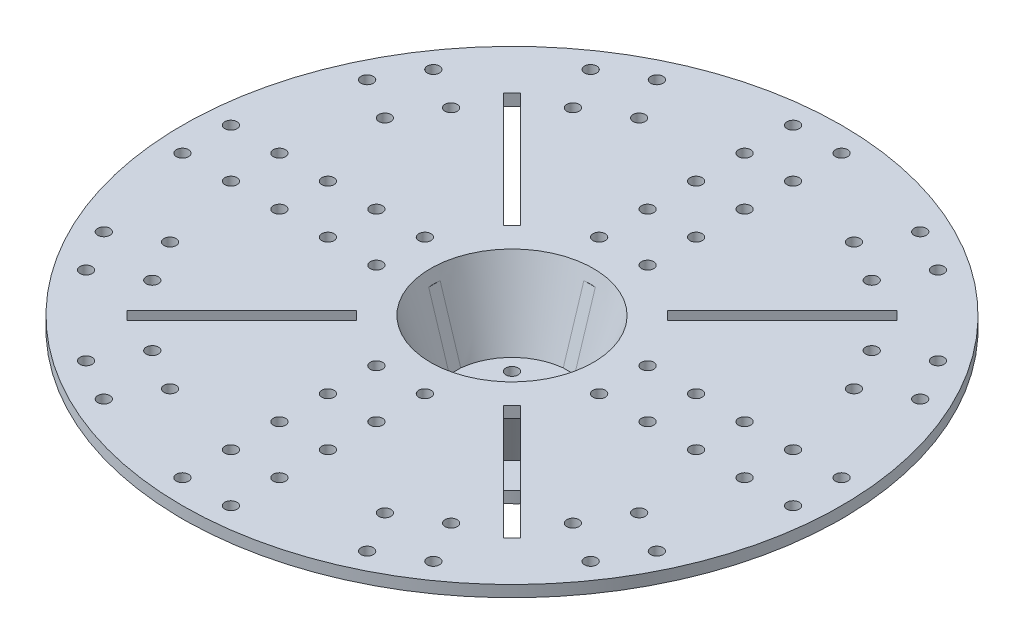
from build123d import *

# Parameters (mm, degrees)
BOSS_EXTRUDE2_DEPTH          = 3
CIRPATTERN2_COUNT            = 4
CUT_EXTRUDE3_DEPTH           = 6
CIRPATTERN4_COUNT            = 4
SKETCH7_W                    = 6
SKETCH7_H                    = 6
CUT_EXTRUDE4_DEPTH           = 34.25
SKETCH8_R                    = 3.175
CUT_EXTRUDE5_DEPTH           = 248.459028351
SKETCH11_R                   = 3.2
CUT_EXTRUDE6_DEPTH           = 248.459028351
LPATTERN2_COUNT              = 2
LPATTERN2_PITCH              = 25.4
LPATTERN2_COUNT_DIR2         = 6
LPATTERN2_PITCH_DIR2         = 25.4
CIRPATTERN5_COUNT            = 4
CIRPATTERN5_COPY_1_SKETCH_R  = 3.2
CIRPATTERN5_COPY_1_DEPTH     = 248.459028351
CIRPATTERN5_COPY_2_SKETCH_R  = 3.2
CIRPATTERN5_COPY_2_DEPTH     = 248.459028351
CIRPATTERN5_COPY_3_SKETCH_R  = 3.2
CIRPATTERN5_COPY_3_DEPTH     = 248.459028351
CIRPATTERN5_COPY_4_SKETCH_R  = 3.2
CIRPATTERN5_COPY_4_DEPTH     = 248.459028351
CIRPATTERN5_COPY_5_SKETCH_R  = 3.2
CIRPATTERN5_COPY_5_DEPTH     = 248.459028351
CIRPATTERN5_COPY_6_SKETCH_R  = 3.2
CIRPATTERN5_COPY_6_DEPTH     = 248.459028351
CIRPATTERN5_COPY_7_SKETCH_R  = 3.2
CIRPATTERN5_COPY_7_DEPTH     = 248.459028351
CIRPATTERN5_COPY_8_SKETCH_R  = 3.2
CIRPATTERN5_COPY_8_DEPTH     = 248.459028351
CIRPATTERN5_COPY_9_SKETCH_R  = 3.2
CIRPATTERN5_COPY_9_DEPTH     = 248.459028351
CIRPATTERN5_COPY_10_SKETCH_R = 3.2
CIRPATTERN5_COPY_10_DEPTH    = 248.459028351
CIRPATTERN5_COPY_11_SKETCH_R = 3.2
CIRPATTERN5_COPY_11_DEPTH    = 248.459028351
CIRPATTERN5_COPY_12_SKETCH_R = 3.2
CIRPATTERN5_COPY_12_DEPTH    = 248.459028351
CIRPATTERN5_COPY_13_SKETCH_R = 3.2
CIRPATTERN5_COPY_13_DEPTH    = 248.459028351
CIRPATTERN5_COPY_14_SKETCH_R = 3.2
CIRPATTERN5_COPY_14_DEPTH    = 248.459028351
CIRPATTERN5_COPY_15_SKETCH_R = 3.2
CIRPATTERN5_COPY_15_DEPTH    = 248.459028351
CIRPATTERN5_COPY_16_SKETCH_R = 3.2
CIRPATTERN5_COPY_16_DEPTH    = 248.459028351
CIRPATTERN5_COPY_17_SKETCH_R = 3.2
CIRPATTERN5_COPY_17_DEPTH    = 248.459028351
CIRPATTERN5_COPY_18_SKETCH_R = 3.2
CIRPATTERN5_COPY_18_DEPTH    = 248.459028351
CIRPATTERN5_COPY_19_SKETCH_R = 3.2
CIRPATTERN5_COPY_19_DEPTH    = 248.459028351
CIRPATTERN5_COPY_20_SKETCH_R = 3.2
CIRPATTERN5_COPY_20_DEPTH    = 248.459028351
CIRPATTERN5_COPY_21_SKETCH_R = 3.2
CIRPATTERN5_COPY_21_DEPTH    = 248.459028351
CIRPATTERN5_COPY_22_SKETCH_R = 3.2
CIRPATTERN5_COPY_22_DEPTH    = 248.459028351
CIRPATTERN5_COPY_23_SKETCH_R = 3.2
CIRPATTERN5_COPY_23_DEPTH    = 248.459028351
CIRPATTERN5_COPY_24_SKETCH_R = 3.2
CIRPATTERN5_COPY_24_DEPTH    = 248.459028351
CIRPATTERN5_COPY_25_SKETCH_R = 3.2
CIRPATTERN5_COPY_25_DEPTH    = 248.459028351
CIRPATTERN5_COPY_26_SKETCH_R = 3.2
CIRPATTERN5_COPY_26_DEPTH    = 248.459028351
CIRPATTERN5_COPY_27_SKETCH_R = 3.2
CIRPATTERN5_COPY_27_DEPTH    = 248.459028351
CIRPATTERN5_COPY_28_SKETCH_R = 3.2
CIRPATTERN5_COPY_28_DEPTH    = 248.459028351
CIRPATTERN5_COPY_29_SKETCH_R = 3.2
CIRPATTERN5_COPY_29_DEPTH    = 248.459028351
CIRPATTERN5_COPY_30_SKETCH_R = 3.2
CIRPATTERN5_COPY_30_DEPTH    = 248.459028351
CIRPATTERN5_COPY_31_SKETCH_R = 3.2
CIRPATTERN5_COPY_31_DEPTH    = 248.459028351
CIRPATTERN5_COPY_32_SKETCH_R = 3.2
CIRPATTERN5_COPY_32_DEPTH    = 248.459028351
CIRPATTERN5_COPY_33_SKETCH_R = 3.2
CIRPATTERN5_COPY_33_DEPTH    = 248.459028351
SKETCH17_R                   = 3.2
CUT_EXTRUDE7_DEPTH           = 249.50547421
LPATTERN3_COUNT              = 2
LPATTERN3_PITCH              = 25.4
LPATTERN3_COUNT_DIR2         = 2
LPATTERN3_PITCH_DIR2         = 25.4
MIRROR1_COPY_1_SKETCH_R      = 3.2
MIRROR1_COPY_1_DEPTH         = 249.50547421
MIRROR1_COPY_2_SKETCH_R      = 3.2
MIRROR1_COPY_2_DEPTH         = 249.50547421
MIRROR1_COPY_3_SKETCH_R      = 3.2
MIRROR1_COPY_3_DEPTH         = 249.50547421
MIRROR2_COPY_1_SKETCH_R      = 3.2
MIRROR2_COPY_1_DEPTH         = 249.50547421
MIRROR2_COPY_2_SKETCH_R      = 3.2
MIRROR2_COPY_2_DEPTH         = 249.50547421
MIRROR2_COPY_3_SKETCH_R      = 3.2
MIRROR2_COPY_3_DEPTH         = 249.50547421
MIRROR2_COPY_4_SKETCH_R      = 3.2
MIRROR2_COPY_4_DEPTH         = 249.50547421
MIRROR2_COPY_5_SKETCH_R      = 3.2
MIRROR2_COPY_5_DEPTH         = 249.50547421
MIRROR2_COPY_6_SKETCH_R      = 3.2
MIRROR2_COPY_6_DEPTH         = 249.50547421
MIRROR2_COPY_7_SKETCH_R      = 3.2
MIRROR2_COPY_7_DEPTH         = 249.50547421
CUT_EXTRUDE8_REACH           = 250.505
CIRPATTERN6_COUNT            = 4
SKETCH23_R                   = 3.2
CUT_EXTRUDE9_DEPTH           = 5.952869
CIRPATTERN7_COUNT            = 2
CIRPATTERN7_ANGLE            = 30
CIRPATTERN8_COUNT            = 4
CIRPATTERN8_COPY_1_SKETCH_R  = 3.2
CIRPATTERN8_COPY_1_DEPTH     = 5.952869
CIRPATTERN8_COPY_2_SKETCH_R  = 3.2
CIRPATTERN8_COPY_2_DEPTH     = 5.952869
CIRPATTERN8_COPY_3_SKETCH_R  = 3.2
CIRPATTERN8_COPY_3_DEPTH     = 5.952869
SKETCH26_R                   = 3.2
CUT_EXTRUDE10_DEPTH          = 249.50547421
LPATTERN4_COUNT              = 2
LPATTERN4_PITCH              = 25.4
LPATTERN4_COUNT_DIR2         = 2
LPATTERN4_PITCH_DIR2         = 25.4
MIRROR3_COPY_1_SKETCH_R      = 3.2
MIRROR3_COPY_1_DEPTH         = 249.50547421
MIRROR3_COPY_2_SKETCH_R      = 3.2
MIRROR3_COPY_2_DEPTH         = 249.50547421
MIRROR3_COPY_3_SKETCH_R      = 3.2
MIRROR3_COPY_3_DEPTH         = 249.50547421
MIRROR4_COPY_1_SKETCH_R      = 3.2
MIRROR4_COPY_1_DEPTH         = 249.50547421
MIRROR4_COPY_2_SKETCH_R      = 3.2
MIRROR4_COPY_2_DEPTH         = 249.50547421
MIRROR4_COPY_3_SKETCH_R      = 3.2
MIRROR4_COPY_3_DEPTH         = 249.50547421
MIRROR4_COPY_4_SKETCH_R      = 3.2
MIRROR4_COPY_4_DEPTH         = 249.50547421
MIRROR4_COPY_5_SKETCH_R      = 3.2
MIRROR4_COPY_5_DEPTH         = 249.50547421
MIRROR4_COPY_6_SKETCH_R      = 3.2
MIRROR4_COPY_6_DEPTH         = 249.50547421
MIRROR4_COPY_7_SKETCH_R      = 3.2
MIRROR4_COPY_7_DEPTH         = 249.50547421
CUT_EXTRUDE11_REACH          = 250.505
SKETCH27_R                   = 3.2
CIRPATTERN9_COUNT            = 4
CUT_EXTRUDE12_REACH          = 252.599
SKETCH28_W                   = 50
SKETCH28_H                   = 6.4
CIRPATTERN10_COUNT           = 4


with BuildPart() as part:
    # Sketch1 → Revolve2 (revolve)
    with BuildSketch(Plane.XY, mode=Mode.PRIVATE) as revolve2_sk:
        Polygon((0, -40.25), (0, -46.25), (55.5, -46.25), (55.5, -40.29713119), (36.117911549, -40.29713119), (46.896841146, -6), (172.649801929, -6), (172.649801929, 0), (42.649801929, 0), (30, -40.25), align=None)
    revolve(revolve2_sk.sketch.rotate(Axis((0, -40.25, 0), (0, -1, 0)), 90), axis=Axis((0, -40.25, 0), (0, -1, 0)))

    # Sketch3 → Boss-Extrude2 (add, symmetric)
    with BuildSketch(Plane.XY):
        Polygon((55.5, -40.29713119), (172.649801929, -6), (0, -6), (0, -40.29713119), align=None)
    boss_extrude2 = extrude(amount=BOSS_EXTRUDE2_DEPTH, both=True)

    # CirPattern2: Boss-Extrude2 ×4 about axis
    cirpattern2_axis = Axis((0, 0, 0), (0, 1, 0))
    for i in range(1, CIRPATTERN2_COUNT):
        add(boss_extrude2.rotate(cirpattern2_axis, i * 360 / CIRPATTERN2_COUNT))

    # Sketch6 → Cut-Extrude3 (cut)
    with BuildSketch(Plane.XY.offset(3)):
        Polygon((-3, -6), (-40.653576086, -6), (-29.849623113, -40.25), (-3, -40.25), align=None)
    cut_extrude3 = extrude(amount=-CUT_EXTRUDE3_DEPTH, mode=Mode.SUBTRACT)

    # CirPattern4: Cut-Extrude3 ×4 about axis
    cirpattern4_axis = Axis((0, 0, 0), (0, 1, 0))
    for i in range(1, CIRPATTERN4_COUNT):
        add(cut_extrude3.rotate(cirpattern4_axis, i * 360 / CIRPATTERN4_COUNT), mode=Mode.SUBTRACT)

    # Sketch7 → Cut-Extrude4 (cut)
    with BuildSketch(Plane(origin=(0, -6, 0), x_dir=(1, 0, 0), z_dir=(0, 1, 0))):
        Rectangle(SKETCH7_W, SKETCH7_H)
    extrude(amount=-CUT_EXTRUDE4_DEPTH, mode=Mode.SUBTRACT)

    # Sketch8 → Cut-Extrude5 (cut, through all)
    with BuildSketch(Plane(origin=(0, -40.25, 0), x_dir=(1, 0, 0), z_dir=(0, 1, 0))):
        with Locations(Location((0, 0, 0), (0, 0, 180))):
            Circle(SKETCH8_R)
    extrude(amount=-CUT_EXTRUDE5_DEPTH, mode=Mode.SUBTRACT)

    # Sketch11 → Cut-Extrude6 (cut, through all)
    with BuildSketch(Plane.XZ.offset(6)):
        with Locations((-12.7, 159.949801929)):
            Circle(SKETCH11_R)
    cut_extrude6 = extrude(amount=-CUT_EXTRUDE6_DEPTH, mode=Mode.SUBTRACT)

    # LPattern2: Cut-Extrude6 2 × 6
    with Locations(*[(i * LPATTERN2_PITCH, 0, -j * LPATTERN2_PITCH_DIR2) for i in range(LPATTERN2_COUNT) for j in range(LPATTERN2_COUNT_DIR2) if (i, j) != (0, 0)]):
        add(cut_extrude6, mode=Mode.SUBTRACT)

    # CirPattern5: Cut-Extrude6 ×4 about axis
    cirpattern5_axis = Axis((0, 0, 0), (0, 1, 0))
    for i in range(1, CIRPATTERN5_COUNT):
        add(cut_extrude6.rotate(cirpattern5_axis, i * 360 / CIRPATTERN5_COUNT), mode=Mode.SUBTRACT)

    # CirPattern5 copy 1 sketch → CirPattern5 copy 1 (cut, through all)
    with BuildSketch(Plane(origin=(-25.4, -6, 0), x_dir=(0, 0, -1), z_dir=(0, -1, 0))):
        with Locations((-12.7, 159.949801929)):
            Circle(CIRPATTERN5_COPY_1_SKETCH_R)
    extrude(amount=-CIRPATTERN5_COPY_1_DEPTH, mode=Mode.SUBTRACT)

    # CirPattern5 copy 2 sketch → CirPattern5 copy 2 (cut, through all)
    with BuildSketch(Plane(origin=(0, -6, 25.4), x_dir=(-1, 0, 0), z_dir=(0, -1, 0))):
        with Locations((-12.7, 159.949801929)):
            Circle(CIRPATTERN5_COPY_2_SKETCH_R)
    extrude(amount=-CIRPATTERN5_COPY_2_DEPTH, mode=Mode.SUBTRACT)

    # CirPattern5 copy 3 sketch → CirPattern5 copy 3 (cut, through all)
    with BuildSketch(Plane(origin=(25.4, -6, 0), x_dir=(0, 0, 1), z_dir=(0, -1, 0))):
        with Locations((-12.7, 159.949801929)):
            Circle(CIRPATTERN5_COPY_3_SKETCH_R)
    extrude(amount=-CIRPATTERN5_COPY_3_DEPTH, mode=Mode.SUBTRACT)

    # CirPattern5 copy 4 sketch → CirPattern5 copy 4 (cut, through all)
    with BuildSketch(Plane(origin=(-50.8, -6, 0), x_dir=(0, 0, -1), z_dir=(0, -1, 0))):
        with Locations((-12.7, 159.949801929)):
            Circle(CIRPATTERN5_COPY_4_SKETCH_R)
    extrude(amount=-CIRPATTERN5_COPY_4_DEPTH, mode=Mode.SUBTRACT)

    # CirPattern5 copy 5 sketch → CirPattern5 copy 5 (cut, through all)
    with BuildSketch(Plane(origin=(0, -6, 50.8), x_dir=(-1, 0, 0), z_dir=(0, -1, 0))):
        with Locations((-12.7, 159.949801929)):
            Circle(CIRPATTERN5_COPY_5_SKETCH_R)
    extrude(amount=-CIRPATTERN5_COPY_5_DEPTH, mode=Mode.SUBTRACT)

    # CirPattern5 copy 6 sketch → CirPattern5 copy 6 (cut, through all)
    with BuildSketch(Plane(origin=(50.8, -6, 0), x_dir=(0, 0, 1), z_dir=(0, -1, 0))):
        with Locations((-12.7, 159.949801929)):
            Circle(CIRPATTERN5_COPY_6_SKETCH_R)
    extrude(amount=-CIRPATTERN5_COPY_6_DEPTH, mode=Mode.SUBTRACT)

    # CirPattern5 copy 7 sketch → CirPattern5 copy 7 (cut, through all)
    with BuildSketch(Plane(origin=(-76.2, -6, 0), x_dir=(0, 0, -1), z_dir=(0, -1, 0))):
        with Locations((-12.7, 159.949801929)):
            Circle(CIRPATTERN5_COPY_7_SKETCH_R)
    extrude(amount=-CIRPATTERN5_COPY_7_DEPTH, mode=Mode.SUBTRACT)

    # CirPattern5 copy 8 sketch → CirPattern5 copy 8 (cut, through all)
    with BuildSketch(Plane(origin=(0, -6, 76.2), x_dir=(-1, 0, 0), z_dir=(0, -1, 0))):
        with Locations((-12.7, 159.949801929)):
            Circle(CIRPATTERN5_COPY_8_SKETCH_R)
    extrude(amount=-CIRPATTERN5_COPY_8_DEPTH, mode=Mode.SUBTRACT)

    # CirPattern5 copy 9 sketch → CirPattern5 copy 9 (cut, through all)
    with BuildSketch(Plane(origin=(76.2, -6, 0), x_dir=(0, 0, 1), z_dir=(0, -1, 0))):
        with Locations((-12.7, 159.949801929)):
            Circle(CIRPATTERN5_COPY_9_SKETCH_R)
    extrude(amount=-CIRPATTERN5_COPY_9_DEPTH, mode=Mode.SUBTRACT)

    # CirPattern5 copy 10 sketch → CirPattern5 copy 10 (cut, through all)
    with BuildSketch(Plane(origin=(-101.6, -6, 0), x_dir=(0, 0, -1), z_dir=(0, -1, 0))):
        with Locations((-12.7, 159.949801929)):
            Circle(CIRPATTERN5_COPY_10_SKETCH_R)
    extrude(amount=-CIRPATTERN5_COPY_10_DEPTH, mode=Mode.SUBTRACT)

    # CirPattern5 copy 11 sketch → CirPattern5 copy 11 (cut, through all)
    with BuildSketch(Plane(origin=(0, -6, 101.6), x_dir=(-1, 0, 0), z_dir=(0, -1, 0))):
        with Locations((-12.7, 159.949801929)):
            Circle(CIRPATTERN5_COPY_11_SKETCH_R)
    extrude(amount=-CIRPATTERN5_COPY_11_DEPTH, mode=Mode.SUBTRACT)

    # CirPattern5 copy 12 sketch → CirPattern5 copy 12 (cut, through all)
    with BuildSketch(Plane(origin=(101.6, -6, 0), x_dir=(0, 0, 1), z_dir=(0, -1, 0))):
        with Locations((-12.7, 159.949801929)):
            Circle(CIRPATTERN5_COPY_12_SKETCH_R)
    extrude(amount=-CIRPATTERN5_COPY_12_DEPTH, mode=Mode.SUBTRACT)

    # CirPattern5 copy 13 sketch → CirPattern5 copy 13 (cut, through all)
    with BuildSketch(Plane(origin=(-127, -6, 0), x_dir=(0, 0, -1), z_dir=(0, -1, 0))):
        with Locations((-12.7, 159.949801929)):
            Circle(CIRPATTERN5_COPY_13_SKETCH_R)
    extrude(amount=-CIRPATTERN5_COPY_13_DEPTH, mode=Mode.SUBTRACT)

    # CirPattern5 copy 14 sketch → CirPattern5 copy 14 (cut, through all)
    with BuildSketch(Plane(origin=(0, -6, 127), x_dir=(-1, 0, 0), z_dir=(0, -1, 0))):
        with Locations((-12.7, 159.949801929)):
            Circle(CIRPATTERN5_COPY_14_SKETCH_R)
    extrude(amount=-CIRPATTERN5_COPY_14_DEPTH, mode=Mode.SUBTRACT)

    # CirPattern5 copy 15 sketch → CirPattern5 copy 15 (cut, through all)
    with BuildSketch(Plane(origin=(127, -6, 0), x_dir=(0, 0, 1), z_dir=(0, -1, 0))):
        with Locations((-12.7, 159.949801929)):
            Circle(CIRPATTERN5_COPY_15_SKETCH_R)
    extrude(amount=-CIRPATTERN5_COPY_15_DEPTH, mode=Mode.SUBTRACT)

    # CirPattern5 copy 16 sketch → CirPattern5 copy 16 (cut, through all)
    with BuildSketch(Plane(origin=(0, -6, -25.4), x_dir=(0, 0, -1), z_dir=(0, -1, 0))):
        with Locations((-12.7, 159.949801929)):
            Circle(CIRPATTERN5_COPY_16_SKETCH_R)
    extrude(amount=-CIRPATTERN5_COPY_16_DEPTH, mode=Mode.SUBTRACT)

    # CirPattern5 copy 17 sketch → CirPattern5 copy 17 (cut, through all)
    with BuildSketch(Plane(origin=(-25.4, -6, 0), x_dir=(-1, 0, 0), z_dir=(0, -1, 0))):
        with Locations((-12.7, 159.949801929)):
            Circle(CIRPATTERN5_COPY_17_SKETCH_R)
    extrude(amount=-CIRPATTERN5_COPY_17_DEPTH, mode=Mode.SUBTRACT)

    # CirPattern5 copy 18 sketch → CirPattern5 copy 18 (cut, through all)
    with BuildSketch(Plane(origin=(0, -6, 25.4), x_dir=(0, 0, 1), z_dir=(0, -1, 0))):
        with Locations((-12.7, 159.949801929)):
            Circle(CIRPATTERN5_COPY_18_SKETCH_R)
    extrude(amount=-CIRPATTERN5_COPY_18_DEPTH, mode=Mode.SUBTRACT)

    # CirPattern5 copy 19 sketch → CirPattern5 copy 19 (cut, through all)
    with BuildSketch(Plane(origin=(-25.4, -6, -25.4), x_dir=(0, 0, -1), z_dir=(0, -1, 0))):
        with Locations((-12.7, 159.949801929)):
            Circle(CIRPATTERN5_COPY_19_SKETCH_R)
    extrude(amount=-CIRPATTERN5_COPY_19_DEPTH, mode=Mode.SUBTRACT)

    # CirPattern5 copy 20 sketch → CirPattern5 copy 20 (cut, through all)
    with BuildSketch(Plane(origin=(-25.4, -6, 25.4), x_dir=(-1, 0, 0), z_dir=(0, -1, 0))):
        with Locations((-12.7, 159.949801929)):
            Circle(CIRPATTERN5_COPY_20_SKETCH_R)
    extrude(amount=-CIRPATTERN5_COPY_20_DEPTH, mode=Mode.SUBTRACT)

    # CirPattern5 copy 21 sketch → CirPattern5 copy 21 (cut, through all)
    with BuildSketch(Plane(origin=(25.4, -6, 25.4), x_dir=(0, 0, 1), z_dir=(0, -1, 0))):
        with Locations((-12.7, 159.949801929)):
            Circle(CIRPATTERN5_COPY_21_SKETCH_R)
    extrude(amount=-CIRPATTERN5_COPY_21_DEPTH, mode=Mode.SUBTRACT)

    # CirPattern5 copy 22 sketch → CirPattern5 copy 22 (cut, through all)
    with BuildSketch(Plane(origin=(-50.8, -6, -25.4), x_dir=(0, 0, -1), z_dir=(0, -1, 0))):
        with Locations((-12.7, 159.949801929)):
            Circle(CIRPATTERN5_COPY_22_SKETCH_R)
    extrude(amount=-CIRPATTERN5_COPY_22_DEPTH, mode=Mode.SUBTRACT)

    # CirPattern5 copy 23 sketch → CirPattern5 copy 23 (cut, through all)
    with BuildSketch(Plane(origin=(-25.4, -6, 50.8), x_dir=(-1, 0, 0), z_dir=(0, -1, 0))):
        with Locations((-12.7, 159.949801929)):
            Circle(CIRPATTERN5_COPY_23_SKETCH_R)
    extrude(amount=-CIRPATTERN5_COPY_23_DEPTH, mode=Mode.SUBTRACT)

    # CirPattern5 copy 24 sketch → CirPattern5 copy 24 (cut, through all)
    with BuildSketch(Plane(origin=(50.8, -6, 25.4), x_dir=(0, 0, 1), z_dir=(0, -1, 0))):
        with Locations((-12.7, 159.949801929)):
            Circle(CIRPATTERN5_COPY_24_SKETCH_R)
    extrude(amount=-CIRPATTERN5_COPY_24_DEPTH, mode=Mode.SUBTRACT)

    # CirPattern5 copy 25 sketch → CirPattern5 copy 25 (cut, through all)
    with BuildSketch(Plane(origin=(-76.2, -6, -25.4), x_dir=(0, 0, -1), z_dir=(0, -1, 0))):
        with Locations((-12.7, 159.949801929)):
            Circle(CIRPATTERN5_COPY_25_SKETCH_R)
    extrude(amount=-CIRPATTERN5_COPY_25_DEPTH, mode=Mode.SUBTRACT)

    # CirPattern5 copy 26 sketch → CirPattern5 copy 26 (cut, through all)
    with BuildSketch(Plane(origin=(-25.4, -6, 76.2), x_dir=(-1, 0, 0), z_dir=(0, -1, 0))):
        with Locations((-12.7, 159.949801929)):
            Circle(CIRPATTERN5_COPY_26_SKETCH_R)
    extrude(amount=-CIRPATTERN5_COPY_26_DEPTH, mode=Mode.SUBTRACT)

    # CirPattern5 copy 27 sketch → CirPattern5 copy 27 (cut, through all)
    with BuildSketch(Plane(origin=(76.2, -6, 25.4), x_dir=(0, 0, 1), z_dir=(0, -1, 0))):
        with Locations((-12.7, 159.949801929)):
            Circle(CIRPATTERN5_COPY_27_SKETCH_R)
    extrude(amount=-CIRPATTERN5_COPY_27_DEPTH, mode=Mode.SUBTRACT)

    # CirPattern5 copy 28 sketch → CirPattern5 copy 28 (cut, through all)
    with BuildSketch(Plane(origin=(-101.6, -6, -25.4), x_dir=(0, 0, -1), z_dir=(0, -1, 0))):
        with Locations((-12.7, 159.949801929)):
            Circle(CIRPATTERN5_COPY_28_SKETCH_R)
    extrude(amount=-CIRPATTERN5_COPY_28_DEPTH, mode=Mode.SUBTRACT)

    # CirPattern5 copy 29 sketch → CirPattern5 copy 29 (cut, through all)
    with BuildSketch(Plane(origin=(-25.4, -6, 101.6), x_dir=(-1, 0, 0), z_dir=(0, -1, 0))):
        with Locations((-12.7, 159.949801929)):
            Circle(CIRPATTERN5_COPY_29_SKETCH_R)
    extrude(amount=-CIRPATTERN5_COPY_29_DEPTH, mode=Mode.SUBTRACT)

    # CirPattern5 copy 30 sketch → CirPattern5 copy 30 (cut, through all)
    with BuildSketch(Plane(origin=(101.6, -6, 25.4), x_dir=(0, 0, 1), z_dir=(0, -1, 0))):
        with Locations((-12.7, 159.949801929)):
            Circle(CIRPATTERN5_COPY_30_SKETCH_R)
    extrude(amount=-CIRPATTERN5_COPY_30_DEPTH, mode=Mode.SUBTRACT)

    # CirPattern5 copy 31 sketch → CirPattern5 copy 31 (cut, through all)
    with BuildSketch(Plane(origin=(-127, -6, -25.4), x_dir=(0, 0, -1), z_dir=(0, -1, 0))):
        with Locations((-12.7, 159.949801929)):
            Circle(CIRPATTERN5_COPY_31_SKETCH_R)
    extrude(amount=-CIRPATTERN5_COPY_31_DEPTH, mode=Mode.SUBTRACT)

    # CirPattern5 copy 32 sketch → CirPattern5 copy 32 (cut, through all)
    with BuildSketch(Plane(origin=(-25.4, -6, 127), x_dir=(-1, 0, 0), z_dir=(0, -1, 0))):
        with Locations((-12.7, 159.949801929)):
            Circle(CIRPATTERN5_COPY_32_SKETCH_R)
    extrude(amount=-CIRPATTERN5_COPY_32_DEPTH, mode=Mode.SUBTRACT)

    # CirPattern5 copy 33 sketch → CirPattern5 copy 33 (cut, through all)
    with BuildSketch(Plane(origin=(127, -6, 25.4), x_dir=(0, 0, 1), z_dir=(0, -1, 0))):
        with Locations((-12.7, 159.949801929)):
            Circle(CIRPATTERN5_COPY_33_SKETCH_R)
    extrude(amount=-CIRPATTERN5_COPY_33_DEPTH, mode=Mode.SUBTRACT)

    # Sketch17 → Cut-Extrude7 (cut, through all)
    with BuildSketch(Plane(origin=(0, 0, 0), x_dir=(1, 0, 0), z_dir=(0, 1, 0))):
        with Locations(Location((132.170591801, -90.973423593, 0), (0, 0, 180))):
            Circle(SKETCH17_R)
    cut_extrude7 = extrude(amount=-CUT_EXTRUDE7_DEPTH, mode=Mode.SUBTRACT)

    # LPattern3: Cut-Extrude7 2 × 2
    with Locations(*[Vector(-0.866025403784438, 0, -0.5000000000000012) * (i * LPATTERN3_PITCH) + Vector(0.500000000000003, 0, -0.866025403784437) * (j * LPATTERN3_PITCH_DIR2) for i in range(LPATTERN3_COUNT) for j in range(LPATTERN3_COUNT_DIR2) if (i, j) != (0, 0)]):
        add(cut_extrude7, mode=Mode.SUBTRACT)

    # Mirror1: Cut-Extrude7 across plane
    add(cut_extrude7.mirror(Plane(origin=(0, 0, 0), x_dir=(0, 0, 1), z_dir=(1, 0, 0))), mode=Mode.SUBTRACT)

    # Mirror1 copy 1 sketch → Mirror1 copy 1 (cut, through all)
    with BuildSketch(Plane(origin=(-12.7, 0, -21.997045256), x_dir=(-1, 0, 0), z_dir=(0, 1, 0))):
        with Locations((132.170591801, 90.973423593)):
            Circle(MIRROR1_COPY_1_SKETCH_R)
    extrude(amount=-MIRROR1_COPY_1_DEPTH, mode=Mode.SUBTRACT)

    # Mirror1 copy 2 sketch → Mirror1 copy 2 (cut, through all)
    with BuildSketch(Plane(origin=(21.997045256, 0, -12.7), x_dir=(-1, 0, 0), z_dir=(0, 1, 0))):
        with Locations((132.170591801, 90.973423593)):
            Circle(MIRROR1_COPY_2_SKETCH_R)
    extrude(amount=-MIRROR1_COPY_2_DEPTH, mode=Mode.SUBTRACT)

    # Mirror1 copy 3 sketch → Mirror1 copy 3 (cut, through all)
    with BuildSketch(Plane(origin=(9.297045256, 0, -34.697045256), x_dir=(-1, 0, 0), z_dir=(0, 1, 0))):
        with Locations((132.170591801, 90.973423593)):
            Circle(MIRROR1_COPY_3_SKETCH_R)
    extrude(amount=-MIRROR1_COPY_3_DEPTH, mode=Mode.SUBTRACT)

    # Mirror2: Cut-Extrude7 across plane
    add(cut_extrude7.mirror(Plane.XY), mode=Mode.SUBTRACT)

    # Mirror2 copy 1 sketch → Mirror2 copy 1 (cut, through all)
    with BuildSketch(Plane(origin=(12.7, 0, 21.997045256), x_dir=(1, 0, 0), z_dir=(0, 1, 0))):
        with Locations((132.170591801, 90.973423593)):
            Circle(MIRROR2_COPY_1_SKETCH_R)
    extrude(amount=-MIRROR2_COPY_1_DEPTH, mode=Mode.SUBTRACT)

    # Mirror2 copy 2 sketch → Mirror2 copy 2 (cut, through all)
    with BuildSketch(Plane(origin=(-21.997045256, 0, 12.7), x_dir=(1, 0, 0), z_dir=(0, 1, 0))):
        with Locations((132.170591801, 90.973423593)):
            Circle(MIRROR2_COPY_2_SKETCH_R)
    extrude(amount=-MIRROR2_COPY_2_DEPTH, mode=Mode.SUBTRACT)

    # Mirror2 copy 3 sketch → Mirror2 copy 3 (cut, through all)
    with BuildSketch(Plane(origin=(-9.297045256, 0, 34.697045256), x_dir=(1, 0, 0), z_dir=(0, 1, 0))):
        with Locations((132.170591801, 90.973423593)):
            Circle(MIRROR2_COPY_3_SKETCH_R)
    extrude(amount=-MIRROR2_COPY_3_DEPTH, mode=Mode.SUBTRACT)

    # Mirror2 copy 4 sketch → Mirror2 copy 4 (cut, through all)
    with BuildSketch(Plane(origin=(0, 0, 0), x_dir=(-1, 0, 0), z_dir=(0, 1, 0))):
        with Locations(Location((132.170591801, -90.973423593, 0), (0, 0, 180))):
            Circle(MIRROR2_COPY_4_SKETCH_R)
    extrude(amount=-MIRROR2_COPY_4_DEPTH, mode=Mode.SUBTRACT)

    # Mirror2 copy 5 sketch → Mirror2 copy 5 (cut, through all)
    with BuildSketch(Plane(origin=(-12.7, 0, 21.997045256), x_dir=(-1, 0, 0), z_dir=(0, 1, 0))):
        with Locations(Location((132.170591801, -90.973423593, 0), (0, 0, 180))):
            Circle(MIRROR2_COPY_5_SKETCH_R)
    extrude(amount=-MIRROR2_COPY_5_DEPTH, mode=Mode.SUBTRACT)

    # Mirror2 copy 6 sketch → Mirror2 copy 6 (cut, through all)
    with BuildSketch(Plane(origin=(21.997045256, 0, 12.7), x_dir=(-1, 0, 0), z_dir=(0, 1, 0))):
        with Locations(Location((132.170591801, -90.973423593, 0), (0, 0, 180))):
            Circle(MIRROR2_COPY_6_SKETCH_R)
    extrude(amount=-MIRROR2_COPY_6_DEPTH, mode=Mode.SUBTRACT)

    # Mirror2 copy 7 sketch → Mirror2 copy 7 (cut, through all)
    with BuildSketch(Plane(origin=(9.297045256, 0, 34.697045256), x_dir=(-1, 0, 0), z_dir=(0, 1, 0))):
        with Locations(Location((132.170591801, -90.973423593, 0), (0, 0, 180))):
            Circle(MIRROR2_COPY_7_SKETCH_R)
    extrude(amount=-MIRROR2_COPY_7_DEPTH, mode=Mode.SUBTRACT)

    # Sketch19 → Cut-Extrude8 (cut, up to next)
    with BuildSketch(Plane(origin=(0, 0, 0), x_dir=(1, 0, 0), z_dir=(0, 1, 0)), mode=Mode.PRIVATE) as cut_extrude8_sk1:
        Polygon((103.131383979, 98.605900579), (98.605900579, 103.131383979), (38.501824178, 43.027307578), (43.027307578, 38.501824178), align=None)
    cut_extrude8_tool1 = extrude(cut_extrude8_sk1.sketch, amount=-CUT_EXTRUDE8_REACH, mode=Mode.PRIVATE) & part.part
    cut_extrude8 = cut_extrude8_tool1.solids().sort_by_distance((70.816604, 0, -70.816604))[0]
    add(cut_extrude8, mode=Mode.SUBTRACT)

    # CirPattern6: Cut-Extrude8 ×4 about axis
    cirpattern6_axis = Axis((0, 0, 0), (0, 1, 0))
    for i in range(1, CIRPATTERN6_COUNT):
        add(cut_extrude8.rotate(cirpattern6_axis, i * 360 / CIRPATTERN6_COUNT), mode=Mode.SUBTRACT)

    # Sketch23 → Cut-Extrude9 (cut)
    with BuildSketch(Plane.XZ.offset(46.25)):
        with Locations(Location((23, -39.837168574, 0), (0, 0, 270))):
            Circle(SKETCH23_R)
    cut_extrude9 = extrude(amount=-CUT_EXTRUDE9_DEPTH, mode=Mode.SUBTRACT)

    # CirPattern7: Cut-Extrude9 ×2 about axis
    cirpattern7_axis = Axis((0, 0, 0), (0, -1, 0))
    for i in range(1, CIRPATTERN7_COUNT):
        add(cut_extrude9.rotate(cirpattern7_axis, i * CIRPATTERN7_ANGLE / (CIRPATTERN7_COUNT - 1)), mode=Mode.SUBTRACT)

    # CirPattern8: Cut-Extrude9 ×4 about axis
    cirpattern8_axis = Axis((0, 0, 0), (0, 1, 0))
    for i in range(1, CIRPATTERN8_COUNT):
        add(cut_extrude9.rotate(cirpattern8_axis, i * 360 / CIRPATTERN8_COUNT), mode=Mode.SUBTRACT)

    # CirPattern8 copy 1 sketch → CirPattern8 copy 1 (cut)
    with BuildSketch(Plane(origin=(0, -46.25, 0), x_dir=(0.5000000000000011, 0, -0.866025403784438), z_dir=(0, -1, 0))):
        with Locations(Location((23, -39.837168574, 0), (0, 0, 270))):
            Circle(CIRPATTERN8_COPY_1_SKETCH_R)
    extrude(amount=-CIRPATTERN8_COPY_1_DEPTH, mode=Mode.SUBTRACT)

    # CirPattern8 copy 2 sketch → CirPattern8 copy 2 (cut)
    with BuildSketch(Plane(origin=(0, -46.25, 0), x_dir=(-0.8660254037844379, 0, -0.5000000000000012), z_dir=(0, -1, 0))):
        with Locations(Location((23, -39.837168574, 0), (0, 0, 270))):
            Circle(CIRPATTERN8_COPY_2_SKETCH_R)
    extrude(amount=-CIRPATTERN8_COPY_2_DEPTH, mode=Mode.SUBTRACT)

    # CirPattern8 copy 3 sketch → CirPattern8 copy 3 (cut)
    with BuildSketch(Plane(origin=(0, -46.25, 0), x_dir=(-0.5000000000000012, 0, 0.8660254037844379), z_dir=(0, -1, 0))):
        with Locations(Location((23, -39.837168574, 0), (0, 0, 270))):
            Circle(CIRPATTERN8_COPY_3_SKETCH_R)
    extrude(amount=-CIRPATTERN8_COPY_3_DEPTH, mode=Mode.SUBTRACT)

    # Sketch26 → Cut-Extrude10 (cut, through all)
    with BuildSketch(Plane(origin=(0, 0, 0), x_dir=(1, 0, 0), z_dir=(0, 1, 0))):
        with Locations(Location((68.976378337, -144.870591801, 0), (0, 0, 180))):
            Circle(SKETCH26_R)
    cut_extrude10 = extrude(amount=-CUT_EXTRUDE10_DEPTH, mode=Mode.SUBTRACT)

    # LPattern4: Cut-Extrude10 2 × 2
    with Locations(*[Vector(-0.500000000000001, 0, -0.866025403784438) * (i * LPATTERN4_PITCH) + Vector(0.8660254037844396, 0, -0.49999999999999845) * (j * LPATTERN4_PITCH_DIR2) for i in range(LPATTERN4_COUNT) for j in range(LPATTERN4_COUNT_DIR2) if (i, j) != (0, 0)]):
        add(cut_extrude10, mode=Mode.SUBTRACT)

    # Mirror3: Cut-Extrude10 across plane
    add(cut_extrude10.mirror(Plane(origin=(0, 0, 0), x_dir=(0, 0, 1), z_dir=(1, 0, 0))), mode=Mode.SUBTRACT)

    # Mirror3 copy 1 sketch → Mirror3 copy 1 (cut, through all)
    with BuildSketch(Plane(origin=(-21.997045256, 0, -12.7), x_dir=(-1, 0, 0), z_dir=(0, 1, 0))):
        with Locations((68.976378337, 144.870591801)):
            Circle(MIRROR3_COPY_1_SKETCH_R)
    extrude(amount=-MIRROR3_COPY_1_DEPTH, mode=Mode.SUBTRACT)

    # Mirror3 copy 2 sketch → Mirror3 copy 2 (cut, through all)
    with BuildSketch(Plane(origin=(12.7, 0, -21.997045256), x_dir=(-1, 0, 0), z_dir=(0, 1, 0))):
        with Locations((68.976378337, 144.870591801)):
            Circle(MIRROR3_COPY_2_SKETCH_R)
    extrude(amount=-MIRROR3_COPY_2_DEPTH, mode=Mode.SUBTRACT)

    # Mirror3 copy 3 sketch → Mirror3 copy 3 (cut, through all)
    with BuildSketch(Plane(origin=(-9.297045256, 0, -34.697045256), x_dir=(-1, 0, 0), z_dir=(0, 1, 0))):
        with Locations((68.976378337, 144.870591801)):
            Circle(MIRROR3_COPY_3_SKETCH_R)
    extrude(amount=-MIRROR3_COPY_3_DEPTH, mode=Mode.SUBTRACT)

    # Mirror4: Cut-Extrude10 across plane
    add(cut_extrude10.mirror(Plane.XY), mode=Mode.SUBTRACT)

    # Mirror4 copy 1 sketch → Mirror4 copy 1 (cut, through all)
    with BuildSketch(Plane(origin=(21.997045256, 0, 12.7), x_dir=(1, 0, 0), z_dir=(0, 1, 0))):
        with Locations((68.976378337, 144.870591801)):
            Circle(MIRROR4_COPY_1_SKETCH_R)
    extrude(amount=-MIRROR4_COPY_1_DEPTH, mode=Mode.SUBTRACT)

    # Mirror4 copy 2 sketch → Mirror4 copy 2 (cut, through all)
    with BuildSketch(Plane(origin=(-12.7, 0, 21.997045256), x_dir=(1, 0, 0), z_dir=(0, 1, 0))):
        with Locations((68.976378337, 144.870591801)):
            Circle(MIRROR4_COPY_2_SKETCH_R)
    extrude(amount=-MIRROR4_COPY_2_DEPTH, mode=Mode.SUBTRACT)

    # Mirror4 copy 3 sketch → Mirror4 copy 3 (cut, through all)
    with BuildSketch(Plane(origin=(9.297045256, 0, 34.697045256), x_dir=(1, 0, 0), z_dir=(0, 1, 0))):
        with Locations((68.976378337, 144.870591801)):
            Circle(MIRROR4_COPY_3_SKETCH_R)
    extrude(amount=-MIRROR4_COPY_3_DEPTH, mode=Mode.SUBTRACT)

    # Mirror4 copy 4 sketch → Mirror4 copy 4 (cut, through all)
    with BuildSketch(Plane(origin=(0, 0, 0), x_dir=(-1, 0, 0), z_dir=(0, 1, 0))):
        with Locations(Location((68.976378337, -144.870591801, 0), (0, 0, 180))):
            Circle(MIRROR4_COPY_4_SKETCH_R)
    extrude(amount=-MIRROR4_COPY_4_DEPTH, mode=Mode.SUBTRACT)

    # Mirror4 copy 5 sketch → Mirror4 copy 5 (cut, through all)
    with BuildSketch(Plane(origin=(-21.997045256, 0, 12.7), x_dir=(-1, 0, 0), z_dir=(0, 1, 0))):
        with Locations(Location((68.976378337, -144.870591801, 0), (0, 0, 180))):
            Circle(MIRROR4_COPY_5_SKETCH_R)
    extrude(amount=-MIRROR4_COPY_5_DEPTH, mode=Mode.SUBTRACT)

    # Mirror4 copy 6 sketch → Mirror4 copy 6 (cut, through all)
    with BuildSketch(Plane(origin=(12.7, 0, 21.997045256), x_dir=(-1, 0, 0), z_dir=(0, 1, 0))):
        with Locations(Location((68.976378337, -144.870591801, 0), (0, 0, 180))):
            Circle(MIRROR4_COPY_6_SKETCH_R)
    extrude(amount=-MIRROR4_COPY_6_DEPTH, mode=Mode.SUBTRACT)

    # Mirror4 copy 7 sketch → Mirror4 copy 7 (cut, through all)
    with BuildSketch(Plane(origin=(-9.297045256, 0, 34.697045256), x_dir=(-1, 0, 0), z_dir=(0, 1, 0))):
        with Locations(Location((68.976378337, -144.870591801, 0), (0, 0, 180))):
            Circle(MIRROR4_COPY_7_SKETCH_R)
    extrude(amount=-MIRROR4_COPY_7_DEPTH, mode=Mode.SUBTRACT)

    # Sketch27 → Cut-Extrude11 (cut, up to next)
    with BuildSketch(Plane.XZ.offset(46.25), mode=Mode.PRIVATE) as cut_extrude11_sk1:
        with Locations((14.849242405, -14.849242405)):
            Circle(SKETCH27_R)
    cut_extrude11_tool1 = extrude(cut_extrude11_sk1.sketch, amount=-CUT_EXTRUDE11_REACH, mode=Mode.PRIVATE) & part.part
    cut_extrude11 = cut_extrude11_tool1.solids().sort_by_distance((14.849242, -46.25, -14.849242))[0]
    add(cut_extrude11, mode=Mode.SUBTRACT)

    # CirPattern9: Cut-Extrude11 ×4 about axis
    cirpattern9_axis = Axis((0, 0, 0), (0, 1, 0))
    for i in range(1, CIRPATTERN9_COUNT):
        add(cut_extrude11.rotate(cirpattern9_axis, i * 360 / CIRPATTERN9_COUNT), mode=Mode.SUBTRACT)

    # Sketch28 → Cut-Extrude12 (cut, up to next)
    with BuildSketch(Plane(origin=(3, 0, 0), x_dir=(0, 0, -1), z_dir=(1, 0, 0)), mode=Mode.PRIVATE) as cut_extrude12_sk1:
        with Locations((76, -15.6)):
            Rectangle(SKETCH28_W, SKETCH28_H)
    cut_extrude12_tool1 = extrude(cut_extrude12_sk1.sketch, amount=-CUT_EXTRUDE12_REACH, mode=Mode.PRIVATE) & part.part
    cut_extrude12 = cut_extrude12_tool1.solids().sort_by_distance((3, -15.6, -76))[0]
    add(cut_extrude12, mode=Mode.SUBTRACT)

    # CirPattern10: Cut-Extrude12 ×4 about axis
    cirpattern10_axis = Axis((0, 0, 0), (0, 1, 0))
    for i in range(1, CIRPATTERN10_COUNT):
        add(cut_extrude12.rotate(cirpattern10_axis, i * 360 / CIRPATTERN10_COUNT), mode=Mode.SUBTRACT)


solid = part.part
